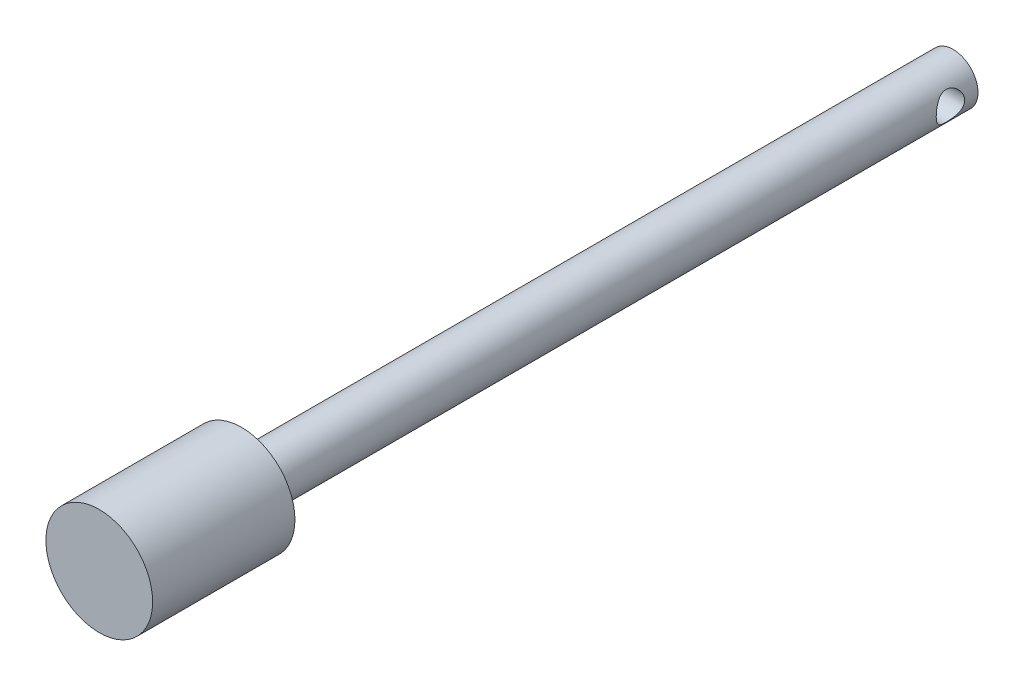
from build123d import *

# Parameters (mm, degrees)
SKETCH1_R               = 3.5
BOSS_EXTRUDE1_DEPTH     = 100
SKETCH2_R               = 7.5
BOSS_EXTRUDE2_DEPTH     = 20
SKETCH3_R               = 2
CUT_EXTRUDE1_DEPTH      = 8.5
CUT_EXTRUDE1_DEPTH_BACK = 8.5


with BuildPart() as part:
    # Sketch1 → Boss-Extrude1 (new body)
    with BuildSketch(Plane.XY):
        Circle(SKETCH1_R)
    extrude(amount=BOSS_EXTRUDE1_DEPTH)

    # Sketch2 → Boss-Extrude2 (add)
    with BuildSketch(Plane.XY.offset(100)):
        Circle(SKETCH2_R)
    extrude(amount=BOSS_EXTRUDE2_DEPTH)

    # Sketch3 → Cut-Extrude1 (cut, two sides)
    with BuildSketch(Plane(origin=(0, 0, 0), x_dir=(0, 0, -1), z_dir=(1, 0, 0))) as cut_extrude1_sk:
        with Locations((-3.868694711, 0)):
            Circle(SKETCH3_R)
    extrude(amount=CUT_EXTRUDE1_DEPTH, mode=Mode.SUBTRACT)
    extrude(cut_extrude1_sk.sketch, amount=-CUT_EXTRUDE1_DEPTH_BACK, mode=Mode.SUBTRACT)


solid = part.part
